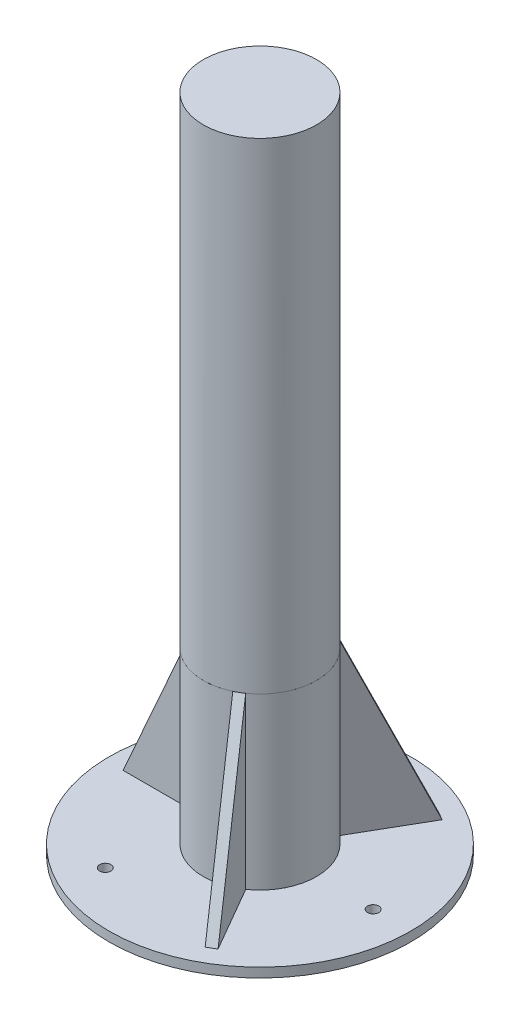
from build123d import *

# Parameters (mm, degrees)
SKETCH1_R           = 80
BOSS_EXTRUDE1_DEPTH = 5
SKETCH2_R           = 30
BOSS_EXTRUDE2_DEPTH = 90
SKETCH3_R           = 30
BOSS_EXTRUDE3_DEPTH = 255
BOSS_EXTRUDE4_DEPTH = 2.5
CIRPATTERN1_COUNT   = 3
SKETCH5_R           = 3
CUT_EXTRUDE1_DEPTH  = 364.077126793


with BuildPart() as part:
    # Sketch1 → Boss-Extrude1 (new body)
    with BuildSketch(Plane(origin=(0, 0, 0), x_dir=(1, 0, 0), z_dir=(0, 1, 0))):
        Circle(SKETCH1_R)
    extrude(amount=-BOSS_EXTRUDE1_DEPTH)


with BuildPart() as body_2:
    # Sketch2 → Boss-Extrude2 (new body)
    with BuildSketch(Plane(origin=(0, 0, 0), x_dir=(1, 0, 0), z_dir=(0, 1, 0))):
        Circle(SKETCH2_R)
    extrude(amount=BOSS_EXTRUDE2_DEPTH)


with BuildPart() as body_3:
    # Sketch3 → Boss-Extrude3 (new body)
    with BuildSketch(Plane(origin=(0, 90, 0), x_dir=(1, 0, 0), z_dir=(0, 1, 0))):
        Circle(SKETCH3_R)
    extrude(amount=BOSS_EXTRUDE3_DEPTH)


with BuildPart() as body_4:
    # Sketch4 → Boss-Extrude4 (new, symmetric)
    with BuildSketch(Plane.XY):
        Polygon((-70, 0), (-30, 0), (-30, 90), align=None)
    boss_extrude4 = extrude(amount=BOSS_EXTRUDE4_DEPTH, both=True)


with BuildPart() as part_1:
    add(part.part)

    # CirPattern1: Boss-Extrude4 ×3 about axis
    cirpattern1_axis = Axis((0, 90, 0), (0, -1, 0))
    for i in range(1, CIRPATTERN1_COUNT):
        add(boss_extrude4.rotate(cirpattern1_axis, i * 360 / CIRPATTERN1_COUNT))

    # Sketch5 → Cut-Extrude1 (cut, through all)
    with BuildSketch(Plane(origin=(0, 0, 0), x_dir=(1, 0, 0), z_dir=(0, 1, 0))):
        with Locations((-30, 51.961524227)):
            Circle(SKETCH5_R)
        with Locations((60, 0)):
            Circle(SKETCH5_R)
        with Locations((-30, -51.961524227)):
            Circle(SKETCH5_R)
    extrude(amount=-CUT_EXTRUDE1_DEPTH, mode=Mode.SUBTRACT)


solid = Compound([body_2.part, body_3.part, body_4.part, part_1.part])
